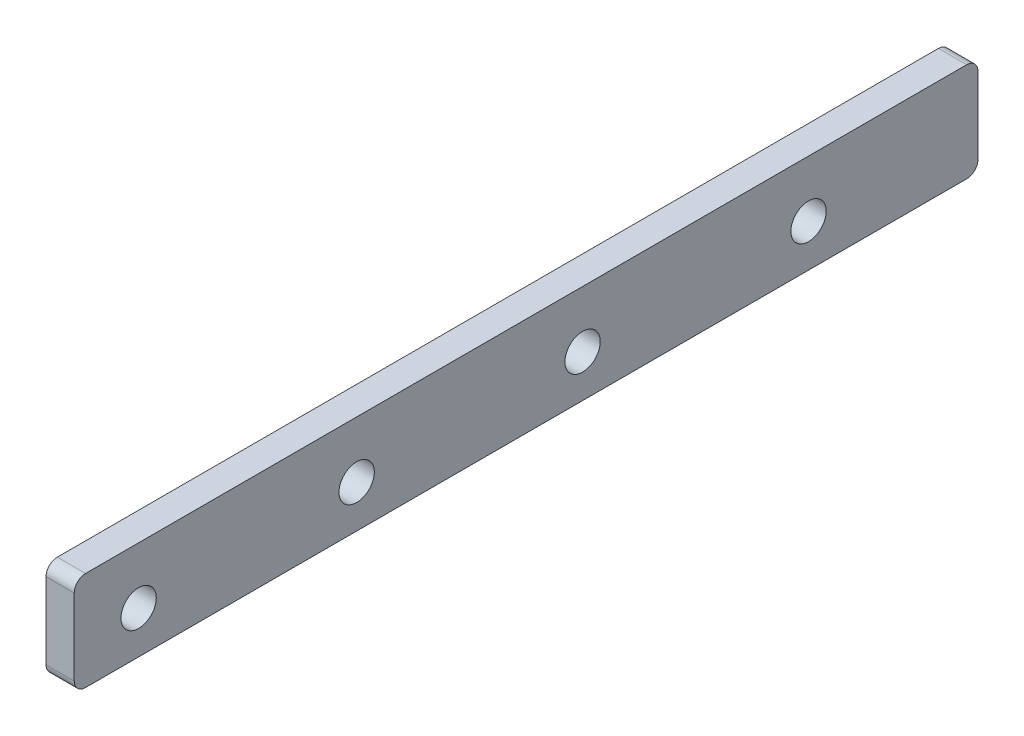
from build123d import *

# Parameters (mm, degrees)
SKETCH1_W           = 203.2
SKETCH1_H           = 22.225
SKETCH1_R           = 3.96875
BOSS_EXTRUDE1_DEPTH = 6.35
FILLET1_R           = 2.54


with BuildPart() as part:
    # Sketch1 → Boss-Extrude1 (new body)
    with BuildSketch(Plane(origin=(0, 0, 0), x_dir=(0, 0, -1), z_dir=(1, 0, 0))):
        with Locations((53.975, 14.2875)):
            Rectangle(SKETCH1_W, SKETCH1_H)
        with Locations((-33.147, 12.7)):
            Circle(SKETCH1_R, mode=Mode.SUBTRACT)
        with Locations((117.475, 12.7)):
            Circle(SKETCH1_R, mode=Mode.SUBTRACT)
        with Locations((15.875, 12.7)):
            Circle(SKETCH1_R, mode=Mode.SUBTRACT)
        with Locations((66.675, 12.7)):
            Circle(SKETCH1_R, mode=Mode.SUBTRACT)
    extrude(amount=BOSS_EXTRUDE1_DEPTH)

    # Fillet1
    fillet1_edges = [part.edges().sort_by_distance(p)[0] for p in [
        (3.175, 25.4, 47.625),
        (3.175, 25.4, -155.575),
        (3.175, 3.175, -155.575),
        (3.175, 3.175, 47.625),
    ]]
    fillet(fillet1_edges, radius=FILLET1_R)


solid = part.part
